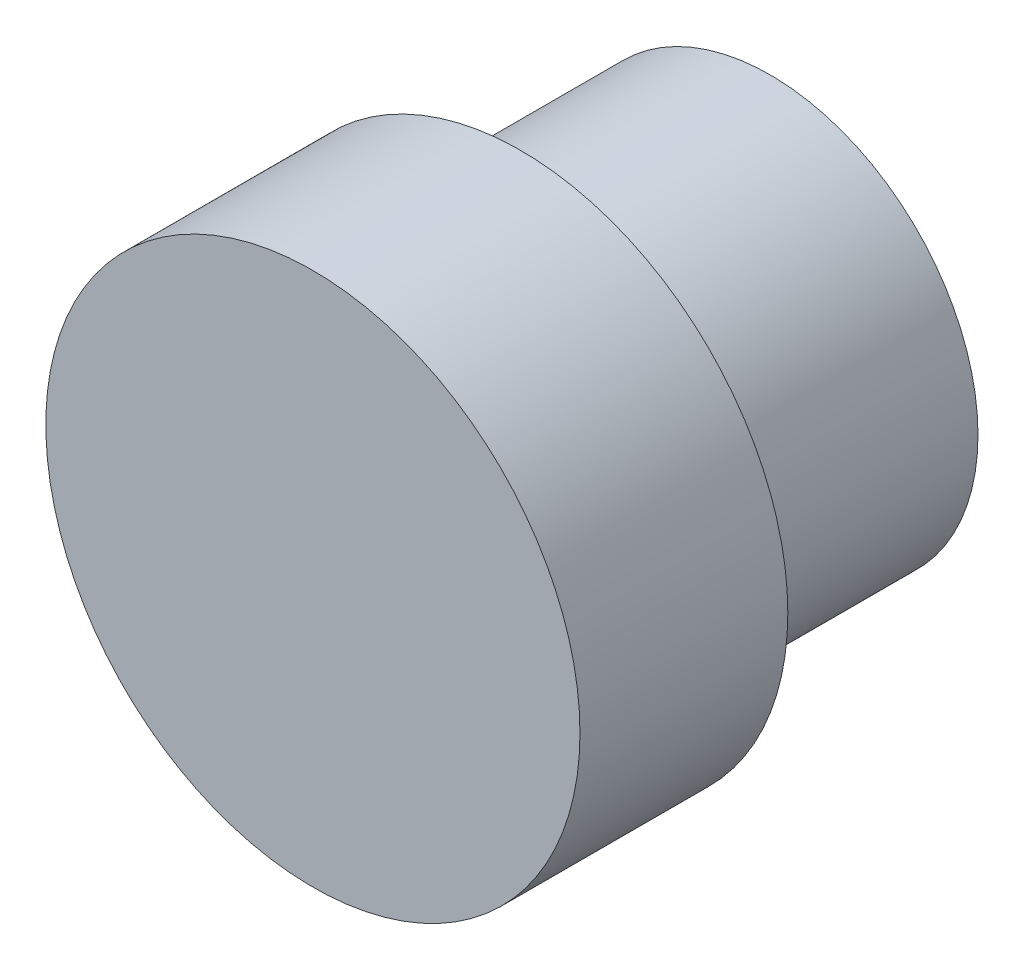
from build123d import *

# Parameters (mm, degrees)
SKETCH2_R           = 5
BOSS_EXTRUDE1_DEPTH = 6
SKETCH3_R           = 6.425
BOSS_EXTRUDE2_DEPTH = 5


with BuildPart() as part:
    # Sketch2 → Boss-Extrude1 (new body)
    with BuildSketch(Plane.XY):
        with Locations((15, 15)):
            Circle(SKETCH2_R)
    extrude(amount=BOSS_EXTRUDE1_DEPTH)

    # Sketch3 → Boss-Extrude2 (add)
    with BuildSketch(Plane.XY.offset(6)):
        with Locations((15, 15)):
            Circle(SKETCH3_R)
    extrude(amount=BOSS_EXTRUDE2_DEPTH)


solid = part.part
